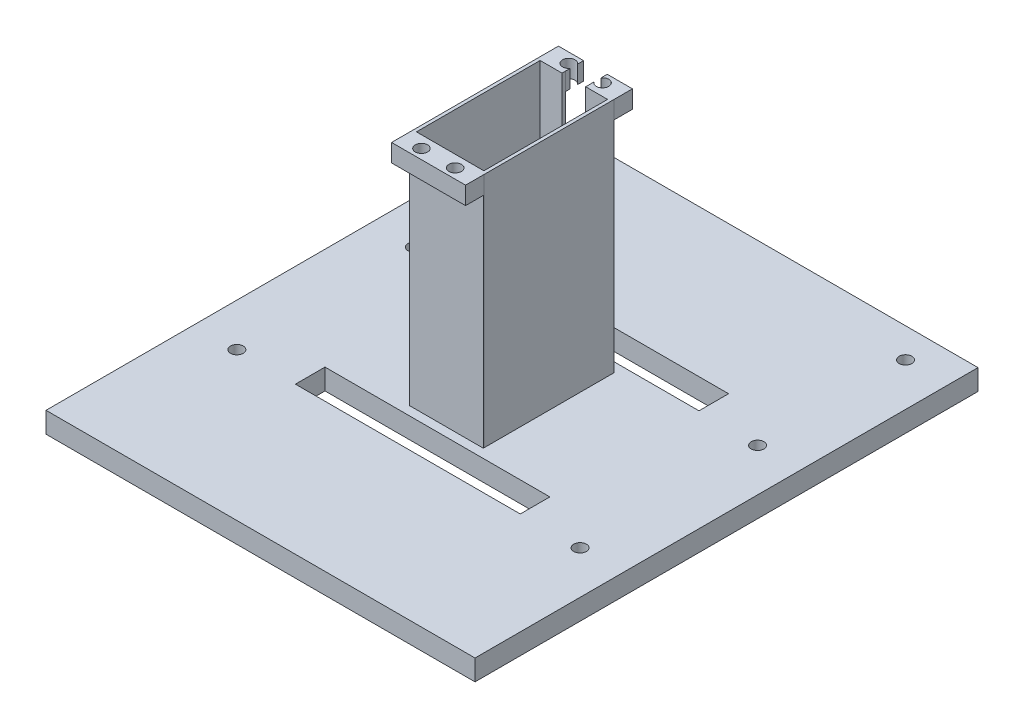
from build123d import *

# Parameters (mm, degrees)
BOSS_EXTRUDE1_DEPTH = 7
BOSS_EXTRUDE2_DEPTH = 80
CUT_EXTRUDE1_DEPTH  = 28
SKETCH4_W           = 8
SKETCH4_H           = 1.100013063
CUT_EXTRUDE2_DEPTH  = 88
SKETCH5_W           = 25
SKETCH5_H           = 80
BOSS_EXTRUDE3_DEPTH = 6.2
SKETCH8_R           = 2.1
CUT_EXTRUDE3_DEPTH  = 6
SKETCH13_W          = 25
SKETCH13_H          = 74
CUT_EXTRUDE11_DEPTH = 6
SKETCH15_W          = 8.5
SKETCH15_H          = 6
BOSS_EXTRUDE6_DEPTH = 6.2
SKETCH16_R          = 2.1
CUT_EXTRUDE12_DEPTH = 6.2
SKETCH17_R          = 2.15
CUT_EXTRUDE13_DEPTH = 8
SKETCH18_W          = 76
SKETCH18_H          = 10
CUT_EXTRUDE14_DEPTH = 8


with BuildPart() as part:
    # Sketch1 → Boss-Extrude1 (new body)
    with BuildSketch(Plane(origin=(0, 0, 0), x_dir=(1, 0, 0), z_dir=(0, 1, 0))):
        Polygon((-72.5, -85), (72.5, -85), (72.5, 85), (12.5, 85), (-12.5, 85), (-72.5, 85), align=None)
    extrude(amount=BOSS_EXTRUDE1_DEPTH)

    # Sketch2 → Boss-Extrude2 (add)
    with BuildSketch(Plane(origin=(0, 7, 0), x_dir=(1, 0, 0), z_dir=(0, 1, 0))):
        Polygon((12.5, 21.999959178), (-12.5, 22), (-12.499999895, -22), (12.500000105, -22.000040822), align=None)
    extrude(amount=BOSS_EXTRUDE2_DEPTH)

    # Sketch3 → Cut-Extrude1 (cut)
    with BuildSketch(Plane(origin=(0, 87, 0), x_dir=(1, 0, 0), z_dir=(0, 1, 0))):
        Polygon((-11.399999997, 20.899998204), (-11.399999897, -20.900001796), (11.400000102, -20.900039025), (11.400000003, 20.899960975), align=None)
    extrude(amount=-CUT_EXTRUDE1_DEPTH, mode=Mode.SUBTRACT)

    # Sketch4 → Cut-Extrude2 (cut, through all)
    with BuildSketch(Plane(origin=(0, 87, 0), x_dir=(1, 0, 0), z_dir=(0, 1, 0))):
        with Locations((0, 21.44997959)):
            Rectangle(SKETCH4_W, SKETCH4_H)
    extrude(amount=-CUT_EXTRUDE2_DEPTH, mode=Mode.SUBTRACT)

    # Sketch5 → Boss-Extrude3 (add)
    with BuildSketch(Plane(origin=(-3.5923e-05, 0, 22.000020411), x_dir=(1, 0, 1.633e-06), z_dir=(-1.633e-06, 0, 1))):
        with Locations((3.6028e-05, 47)):
            Rectangle(SKETCH5_W, SKETCH5_H)
    extrude(amount=BOSS_EXTRUDE3_DEPTH)

    # Sketch8 → Cut-Extrude3 (cut)
    with BuildSketch(Plane(origin=(0, 87, 0), x_dir=(1, 0, 0), z_dir=(0, 1, 0))):
        with Locations((5.700000051, -24.900029718)):
            Circle(SKETCH8_R)
        with Locations((-5.700000051, -24.900029718)):
            Circle(SKETCH8_R)
    extrude(amount=-CUT_EXTRUDE3_DEPTH, mode=Mode.SUBTRACT)

    # Sketch13 → Cut-Extrude11 (cut)
    with BuildSketch(Plane(origin=(-4.6047e-05, 0, 28.200020411), x_dir=(1, 0, 1.633e-06), z_dir=(-1.633e-06, 0, 1))):
        with Locations((3.6028e-05, 44)):
            Rectangle(SKETCH13_W, SKETCH13_H)
    extrude(amount=-CUT_EXTRUDE11_DEPTH, mode=Mode.SUBTRACT)

    # Sketch15 → Boss-Extrude6 (add)
    with BuildSketch(Plane(origin=(3.5923e-05, 0, -21.999979589), x_dir=(-1, 0, -1.633e-06), z_dir=(1.633e-06, 0, -1))):
        with Locations((-8.249964077, 84)):
            Rectangle(SKETCH15_W, SKETCH15_H)
        with Locations((8.249964077, 84)):
            Rectangle(SKETCH15_W, SKETCH15_H)
    extrude(amount=BOSS_EXTRUDE6_DEPTH)

    # Sketch16 → Cut-Extrude12 (cut)
    with BuildSketch(Plane(origin=(0, 87, 0), x_dir=(1, 0, 0), z_dir=(0, 1, 0))):
        with Locations((5.700000051, -24.900029718)):
            Circle(SKETCH16_R)
        with Locations((-5.700000051, -24.900029718)):
            Circle(SKETCH16_R)
        with Locations((5.700000051, 24.900029718)):
            Circle(SKETCH16_R)
        with Locations((-5.700000051, 24.900029718)):
            Circle(SKETCH16_R)
    extrude(amount=-CUT_EXTRUDE12_DEPTH, mode=Mode.SUBTRACT)

    # Sketch17 → Cut-Extrude13 (cut, through all)
    with BuildSketch(Plane(origin=(0, 7, 0), x_dir=(1, 0, 0), z_dir=(0, 1, 0))):
        with Locations((-58, 75)):
            Circle(SKETCH17_R)
        with Locations((-58, 25)):
            Circle(SKETCH17_R)
        with Locations((-58, -35)):
            Circle(SKETCH17_R)
        with Locations((58, -35)):
            Circle(SKETCH17_R)
        with Locations((58, 25)):
            Circle(SKETCH17_R)
        with Locations((58, 75)):
            Circle(SKETCH17_R)
    extrude(amount=-CUT_EXTRUDE13_DEPTH, mode=Mode.SUBTRACT)

    # Sketch18 → Cut-Extrude14 (cut, through all)
    with BuildSketch(Plane(origin=(0, 7, 0), x_dir=(1, 0, 0), z_dir=(0, 1, 0))):
        with Locations((0, 30.200020411)):
            Rectangle(SKETCH18_W, SKETCH18_H)
        with Locations((0, -30.200020411)):
            Rectangle(SKETCH18_W, SKETCH18_H)
    extrude(amount=-CUT_EXTRUDE14_DEPTH, mode=Mode.SUBTRACT)


solid = part.part
